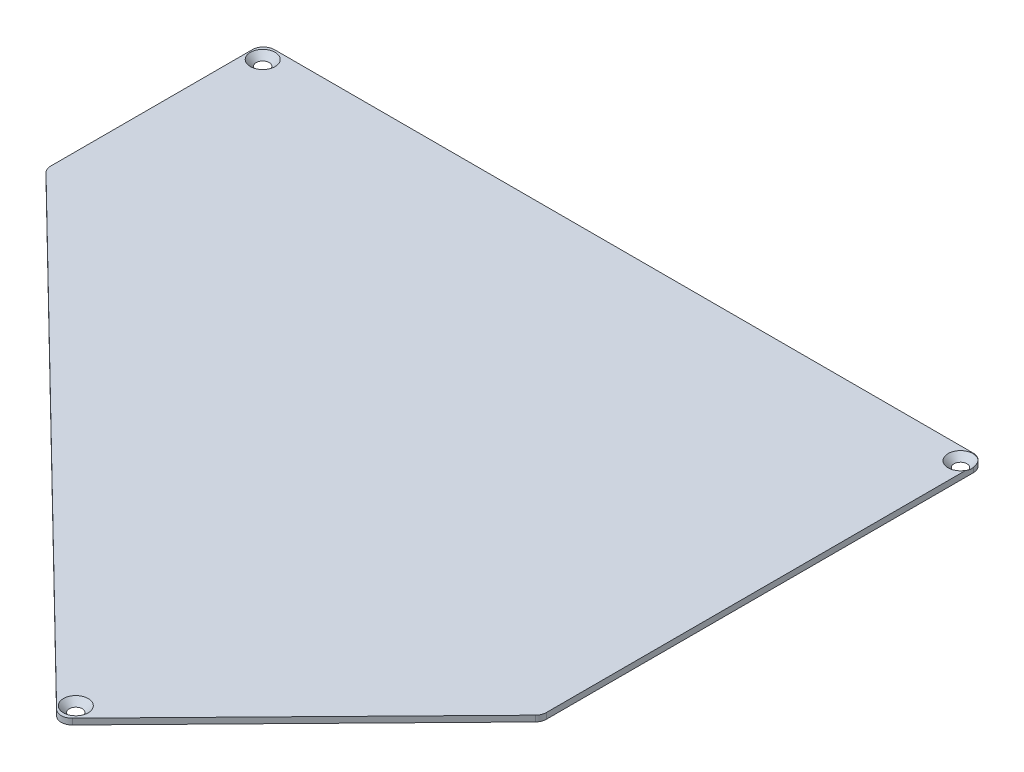
from build123d import *

# Parameters (mm, degrees)
BOSS_EXTRUDE2_DEPTH                            = 1.5
CSK_FOR_M3_FLAT_HEAD_MACHINE_SCREW1_AT_2_COUNT = 2
CSK_FOR_M3_FLAT_HEAD_MACHINE_SCREW1_AT_2_PITCH = 177.040281246
CSK_FOR_M3_FLAT_HEAD_MACHINE_SCREW1_AT_3_COUNT = 2
CSK_FOR_M3_FLAT_HEAD_MACHINE_SCREW1_AT_3_PITCH = 203.995944874


with BuildPart() as part:
    # Sketch1 → Boss-Extrude2 (new body)
    with BuildSketch(Plane(origin=(0, 0, 0), x_dir=(1, 0, 0), z_dir=(0, 1, 0))):
        with BuildLine():
            Line((85.023837811, -74.381167696), (143.225208545, -14.836107228))
            ThreePointArc((143.225208545, -14.836107228), (143.81578007, -13.935666345), (144.022845875, -12.878929736))
            Line((144.022845875, -12.878929736), (144.022845875, 95.704196999))
            ThreePointArc((144.022845875, 95.704196999), (143.202744862, 97.684095986), (141.222845875, 98.504196999))
            Line((141.222845875, 98.504196999), (-36.49118484, 98.504196999))
            ThreePointArc((-36.49118484, 98.504196999), (-38.471083828, 97.684095986), (-39.29118484, 95.704196999))
            Line((-39.29118484, 95.704196999), (-39.29118484, 44.391755323))
            ThreePointArc((-39.29118484, 44.391755323), (-39.071891815, 43.305499593), (-38.448362333, 42.389392653))
            Line((-38.448362333, 42.389392653), (81.064297648, -74.426352874))
            ThreePointArc((81.064297648, -74.426352874), (83.053425886, -75.223807903), (85.023837811, -74.381167696))
        make_face()
    extrude(amount=BOSS_EXTRUDE2_DEPTH)

    # Sketch3 → CSK for M3 Flat Head Machine Screw1 (revolve, cut)
    with BuildSketch(Plane(origin=(-35.810496246, 1.5, -94.85013004), x_dir=(0, 0, 1), z_dir=(1, 0, 0))):
        Polygon((0, 0), (0, 1.5), (1.6, 1.5), (1.6, 1.55), (3.15, 0), align=None)
    csk_for_m3_flat_head_machine_screw1 = revolve(axis=Axis((-35.810496246, 7.85, -94.85013004), (0, -1, 0)), mode=Mode.SUBTRACT)

    # CSK for M3 Flat Head Machine Screw1 at 2: CSK for M3 Flat Head Machine Screw1 ×2
    with Locations(*[Vector(0.999998, 0, -0.001999923) * (i * CSK_FOR_M3_FLAT_HEAD_MACHINE_SCREW1_AT_2_PITCH) for i in range(1, CSK_FOR_M3_FLAT_HEAD_MACHINE_SCREW1_AT_2_COUNT)]):
        add(csk_for_m3_flat_head_machine_screw1, mode=Mode.SUBTRACT)

    # CSK for M3 Flat Head Machine Screw1 at 3: CSK for M3 Flat Head Machine Screw1 ×2
    with Locations(*[Vector(0.580964274, 0, 0.813929058) * (i * CSK_FOR_M3_FLAT_HEAD_MACHINE_SCREW1_AT_3_PITCH) for i in range(1, CSK_FOR_M3_FLAT_HEAD_MACHINE_SCREW1_AT_3_COUNT)]):
        add(csk_for_m3_flat_head_machine_screw1, mode=Mode.SUBTRACT)


solid = part.part
